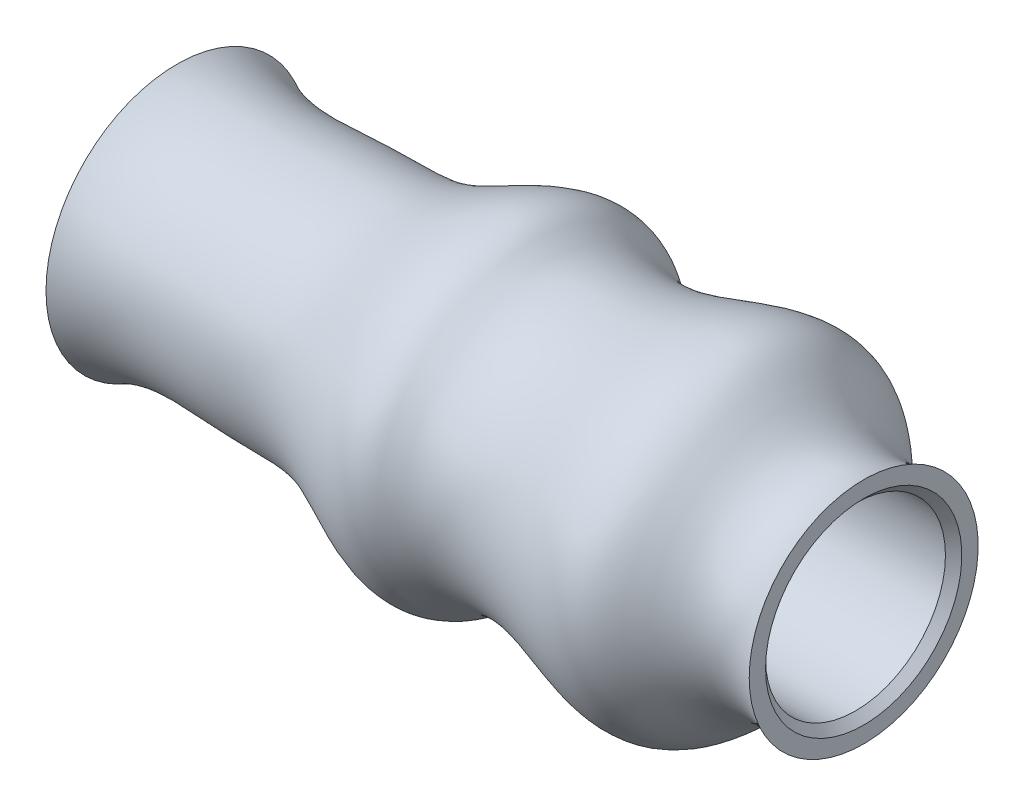
from build123d import *

# Parameters (mm, degrees)
CHANFREIN4_SIZE = 0.5


with BuildPart() as part:
    # Esquisse1 → Base-Révolution (revolve)
    with BuildSketch(Plane.XY, mode=Mode.PRIVATE) as base_r_volution_sk:
        with BuildLine():
            Line((0, 7.228416147), (0, 8))
            add(Edge.make_bspline(
                [(0, 8), (2.710486751, 6.571306957), (7.554112681, 7.409869736), (14.490718914, 6.910977773), (19.758402328, 11.163876116), (23.628444764, 7.958140122), (28.51167236, 8.530202025), (35.801513751, 11.908208161), (38.337815251, 5.17521673), (42, 7)],
                knots=[0, 0, 0, 0, 0.207610209, 0.324502855, 0.503256275, 0.537353243, 0.665472533, 0.817129399, 1, 1, 1, 1], degree=3))
            Line((42, 7), (42, 5.5))
            Line((42, 5.5), (7, 5.5))
            Line((7, 5.5), (7, 2.5))
            Line((7, 2.5), (5.071067812, 2.5))
            ThreePointArc((5.071067812, 2.5), (3.114738276, 5.485385344), (0, 7.228416147))
        make_face()
    revolve(base_r_volution_sk.sketch.rotate(Axis((-84.213521127, 0, 0), (1, 0, 0)), 90), axis=Axis((-84.213521127, 0, 0), (1, 0, 0)))  # turned: the seam where the file's is

    # Chanfrein4
    chanfrein4_edges = [part.edges().sort_by_distance(p)[0] for p in [
        (42, 0, -5.5),
    ]]
    chamfer(chanfrein4_edges, length=CHANFREIN4_SIZE)


solid = part.part
